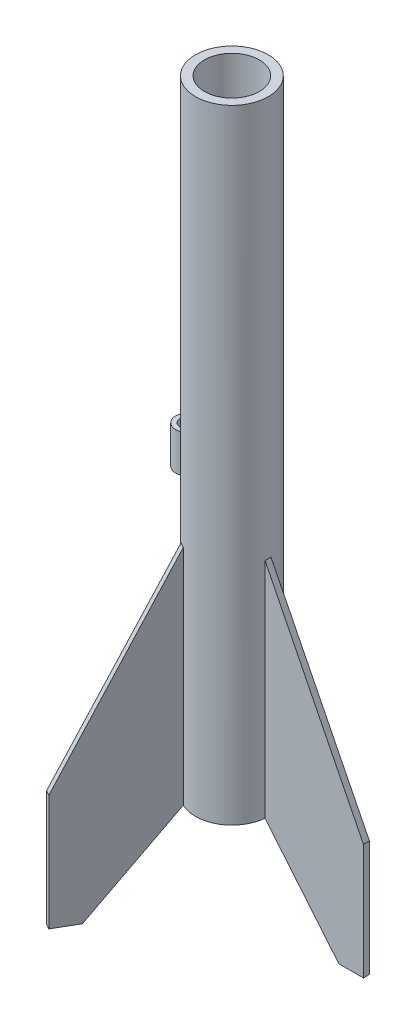
from build123d import *

# Parameters (mm, degrees)
SKETCH2_R                = 12.25
SKETCH2_R_2              = 9.25
BOSS_EXTRUDE1_DEPTH      = 210
SKETCH5_R                = 9.5
SKETCH5_R_2              = 4.625
BOSS_EXTRUDE2_DEPTH      = 12
BOSS_EXTRUDE3_DEPTH      = 1
CIRPATTERN1_COUNT        = 3
BOSS_EXTRUDE4_DEPTH      = 6.35
BOSS_EXTRUDE4_DEPTH_BACK = 6.35
SKETCH8_R                = 4
SKETCH8_R_2              = 2.5
SKETCH9_W                = 2
SKETCH9_H                = 19.5


with BuildPart() as part:
    # Sketch2 → Boss-Extrude1 (new body)
    with BuildSketch(Plane(origin=(-2.465768249, 0, -0.081027564), x_dir=(1, 0, 0), z_dir=(0, 1, 0))):
        with Locations((2.411661176, 0)):
            Circle(SKETCH2_R)
        with Locations((2.411661176, 0)):
            Circle(SKETCH2_R_2, mode=Mode.SUBTRACT)
    extrude(amount=BOSS_EXTRUDE1_DEPTH)

    # Sketch5 → Boss-Extrude2 (add)
    with BuildSketch(Plane(origin=(0, 60, 0), x_dir=(1, 0, 0), z_dir=(0, 1, 0))):
        with Locations((-0.054107074, 0.081027564)):
            Circle(SKETCH5_R)
        with Locations((-0.054107074, 0.081027564)):
            Circle(SKETCH5_R_2, mode=Mode.SUBTRACT)
    extrude(amount=BOSS_EXTRUDE2_DEPTH)

    # Sketch7 → Boss-Extrude3 (add, symmetric)
    with BuildSketch(Plane.XY):
        Polygon((12.195892926, 75.2), (9.828211369, 75.2), (11.195892926, 0), (12.195892926, 0), (37.059460314, -30), (45.34731611, -30), (45.34731611, 9), align=None)
    boss_extrude3 = extrude(amount=BOSS_EXTRUDE3_DEPTH, both=True)

    # CirPattern1: Boss-Extrude3 ×3 about axis
    cirpattern1_axis = Axis((-0.054107074, 210, -0.081027564), (0, -1, 0))
    for i in range(1, CIRPATTERN1_COUNT):
        add(boss_extrude3.rotate(cirpattern1_axis, i * 360 / CIRPATTERN1_COUNT))

    # Sketch8 → Boss-Extrude4 (add, two sides: drawn at the far end of the back side and taken through both)
    with BuildSketch(Plane(origin=(0.379836366, 95, 0), x_dir=(1, 0, 0), z_dir=(0, 1, 0)).offset(-BOSS_EXTRUDE4_DEPTH_BACK)):
        with Locations((-15.3, 0)):
            Circle(SKETCH8_R)
        with Locations((-15.3, 0)):
            Circle(SKETCH8_R_2, mode=Mode.SUBTRACT)
    extrude(amount=BOSS_EXTRUDE4_DEPTH + BOSS_EXTRUDE4_DEPTH_BACK)

    # Sketch9 → Revolve-Thin1 (revolve)
    with BuildSketch(Plane(origin=(0, 110, 0), x_dir=(1, 0, 0), z_dir=(0, 1, 0))):
        with Locations((-2.5, 0.25)):
            Rectangle(SKETCH9_W, SKETCH9_H)
    revolve(axis=Axis((-3.5, 110, -10), (0, 0, 1)))


solid = part.part
